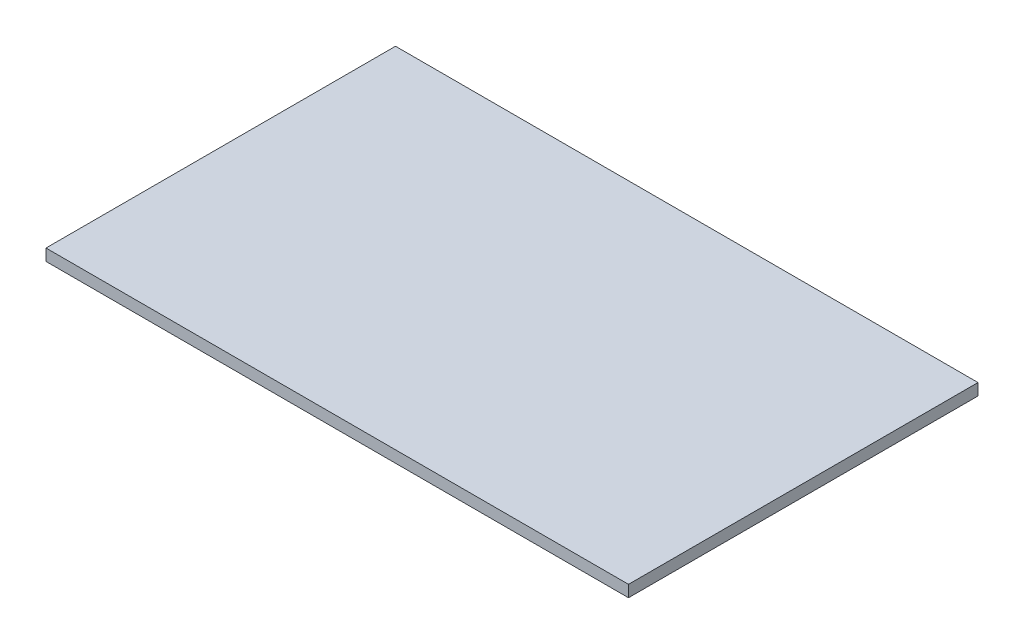
from build123d import *

# Parameters (mm, degrees)
SKETCH1_W           = 127
SKETCH1_H           = 76.2
BOSS_EXTRUDE1_DEPTH = 2.54


with BuildPart() as part:
    # Sketch1 → Boss-Extrude1 (new body)
    with BuildSketch(Plane(origin=(0, 0, 0), x_dir=(1, 0, 0), z_dir=(0, 1, 0))):
        with Locations((8.469264082, -10.156932021)):
            Rectangle(SKETCH1_W, SKETCH1_H)
    extrude(amount=BOSS_EXTRUDE1_DEPTH)


solid = part.part
